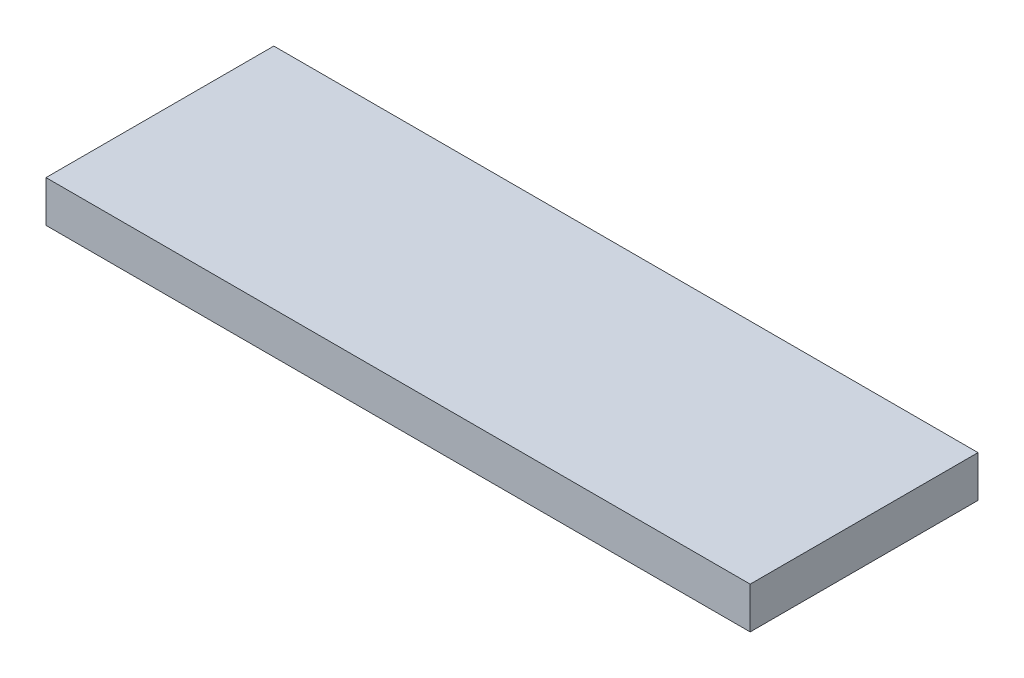
from build123d import *

# Parameters (mm, degrees)
SKETCH1_W           = 170
SKETCH1_H           = 55
BOSS_EXTRUDE1_DEPTH = 10


with BuildPart() as part:
    # Sketch1 → Boss-Extrude1 (new body)
    with BuildSketch(Plane(origin=(0, 0, 0), x_dir=(1, 0, 0), z_dir=(0, 1, 0))):
        with Locations((-11.06741573, -9.634831461)):
            Rectangle(SKETCH1_W, SKETCH1_H)
    extrude(amount=BOSS_EXTRUDE1_DEPTH)


solid = part.part
